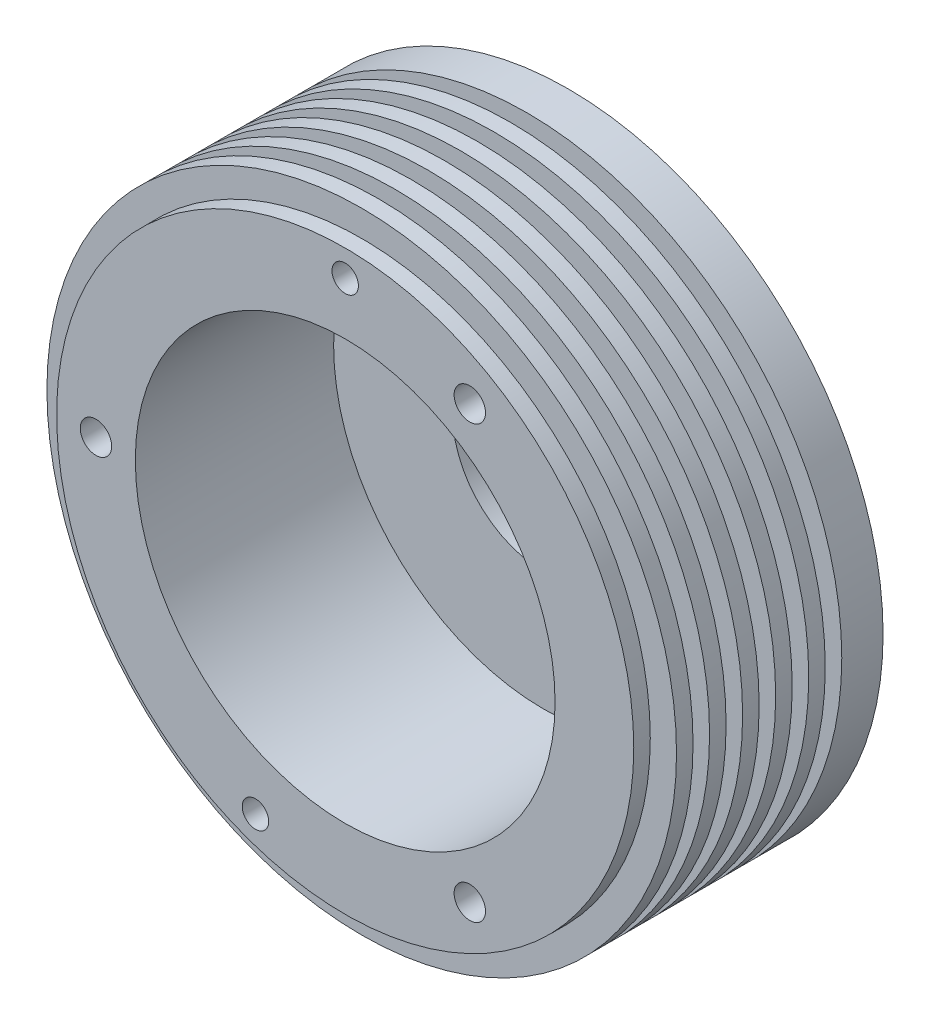
from build123d import *

# Parameters (mm, degrees)
ESQUISSE1_R                          = 38.1
BOSS_EXTRU_1_DEPTH                   = 27
ESQUISSE3_R                          = 25.4
ENL_V_MAT_EXTRU_2_DEPTH              = 24
ESQUISSE5_R                          = 11
ENL_V_MAT_EXTRU_3_DEPTH              = 3
ESQUISSE8_R                          = 38.1
ESQUISSE8_R_2                        = 34.925
ENL_V_MAT_EXTRU_5_DEPTH              = 2
R_P_TITION_LIN_AIRE1_COUNT           = 6
R_P_TITION_LIN_AIRE1_PITCH           = 4
D_GAGEMENT_61_D                      = 3.7973
F_1_8_0_126_TROUS_DE_CENTRAGE1_D     = 3.2004
F_1_8_0_126_TROUS_DE_CENTRAGE1_DEPTH = 27
F_1_8_0_126_TROUS_DE_CENTRAGE1_TIP   = 0.961497163


with BuildPart() as part:
    # Esquisse1 → Boss.-Extru.1 (new body)
    with BuildSketch(Plane.XY):
        with Locations((23.679503876, 29.670703652)):
            Circle(ESQUISSE1_R)
    extrude(amount=BOSS_EXTRU_1_DEPTH)

    # Esquisse3 → Enlèv. mat.-Extru.2 (cut)
    with BuildSketch(Plane.XY.offset(27)):
        with Locations((23.679503876, 29.670703652)):
            Circle(ESQUISSE3_R)
    extrude(amount=-ENL_V_MAT_EXTRU_2_DEPTH, mode=Mode.SUBTRACT)

    # Esquisse5 → Enlèv. mat.-Extru.3 (cut)
    with BuildSketch(Plane(origin=(0, 0, 0), x_dir=(-1, 0, 0), z_dir=(0, 0, -1))):
        with Locations((-23.679503876, 29.670703652)):
            Circle(ESQUISSE5_R)
    extrude(amount=-ENL_V_MAT_EXTRU_3_DEPTH, mode=Mode.SUBTRACT)

    # Esquisse8 → Enlèv. mat.-Extru.5 (cut)
    with BuildSketch(Plane.XY.offset(27)):
        with Locations((23.679503876, 29.670703652)):
            Circle(ESQUISSE8_R)
        with Locations((23.679503876, 29.670703652)):
            Circle(ESQUISSE8_R_2, mode=Mode.SUBTRACT)
    enl_v_mat_extru_5 = extrude(amount=-ENL_V_MAT_EXTRU_5_DEPTH, mode=Mode.SUBTRACT)

    # Répétition linéaire1: Enlèv. mat.-Extru.5 ×6
    with Locations(*[(0, 0, -i * R_P_TITION_LIN_AIRE1_PITCH) for i in range(1, R_P_TITION_LIN_AIRE1_COUNT)]):
        add(enl_v_mat_extru_5, mode=Mode.SUBTRACT)

    # Dégagement #61 (through all)
    with Locations(Plane(origin=(0, 0, 0), x_dir=(-1, 0, 0), z_dir=(0, 0, -1))):
        with Locations((-38.760753876, 55.792194893), (6.482996124, 29.670703652), (-38.760753876, 3.54921241)):
            Hole(D_GAGEMENT_61_D / 2)

    # 1/8 (0.126) Trous de centrage1
    with Locations(Plane(origin=(0, 0, 0), x_dir=(-1, 0, 0), z_dir=(0, 0, -1))):
        with Locations((-23.679503876, 61.420703652), (-12.820364325, -0.164537058)):
            Hole(F_1_8_0_126_TROUS_DE_CENTRAGE1_D / 2, depth=F_1_8_0_126_TROUS_DE_CENTRAGE1_DEPTH)
            with Locations((0, 0, -(F_1_8_0_126_TROUS_DE_CENTRAGE1_DEPTH + F_1_8_0_126_TROUS_DE_CENTRAGE1_TIP / 2))):  # 118° drill point
                Cone(0, F_1_8_0_126_TROUS_DE_CENTRAGE1_D / 2, F_1_8_0_126_TROUS_DE_CENTRAGE1_TIP, mode=Mode.SUBTRACT)


solid = part.part
